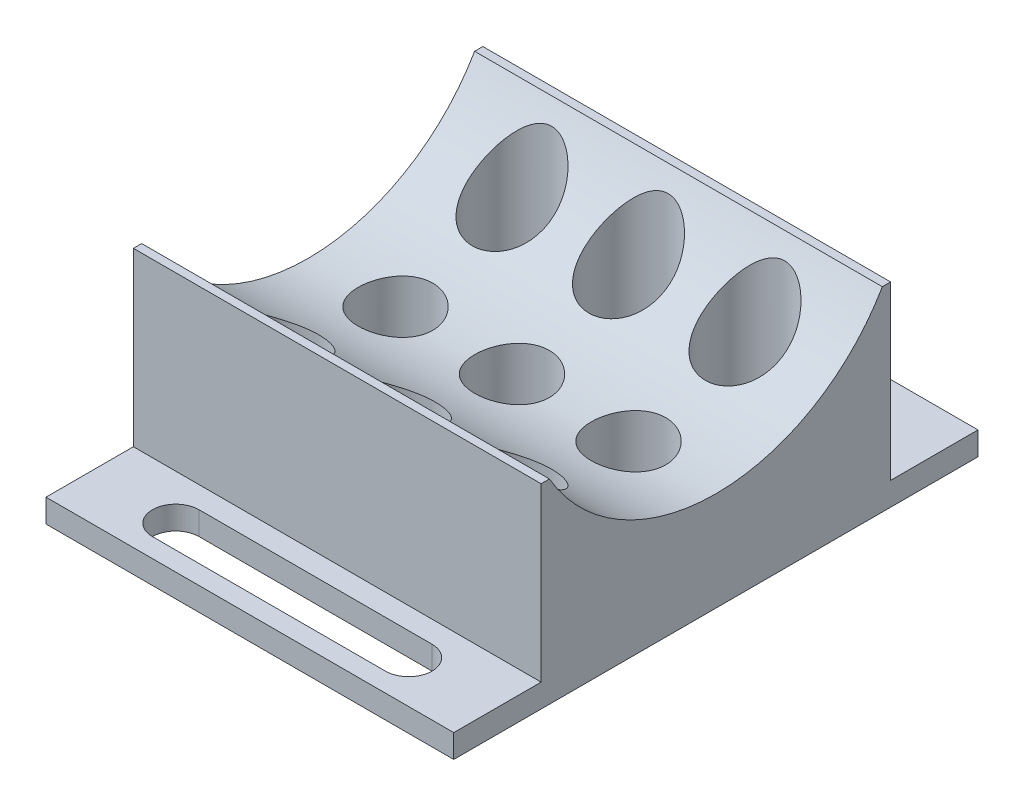
from build123d import *

# Parameters (mm, degrees)
SKETCH8_W                       = 35
SKETCH8_H                       = 30
BOSS_EXTRUDE7_DEPTH             = 80
SKETCH10_R                      = 16.5
CUT_EXTRUDE3_DEPTH              = 18.5
CUT_EXTRUDE3_DEPTH_BACK         = 18.5
SKETCH11_W                      = 38.336381606
SKETCH11_H                      = 16.50007926
CUT_EXTRUDE4_DEPTH              = 18.5
CUT_EXTRUDE4_DEPTH_BACK         = 18.5
SKETCH12_W                      = 33.824881692
SKETCH12_H                      = 15
CUT_EXTRUDE5_DEPTH              = 18.5
CUT_EXTRUDE5_DEPTH_BACK         = 18.5
SKETCH13_W                      = 45.541829225
SKETCH13_H                      = 41.48776408
CUT_EXTRUDE6_DEPTH              = 18.5
CUT_EXTRUDE6_DEPTH_BACK         = 18.5
SKETCH15_W                      = 35
SKETCH15_H                      = 7.5
BOSS_EXTRUDE9_DEPTH             = 2
CUT_EXTRUDE7_DEPTH              = 2
SKETCH18_R                      = 3.2
CUT_EXTRUDE10_DEPTH             = 9.24996037
CUT_EXTRUDE10_DEPTH_BACK        = 6.4
CUT_EXTRUDE11_REACH             = 10.25
SKETCH19_R                      = 3.4
CUT_EXTRUDE11_DIRECTION_2_DEPTH = 4.9


with BuildPart() as part:
    # Sketch8 → Boss-Extrude7 (new body)
    with BuildSketch(Plane(origin=(0, 0, 0), x_dir=(1, 0, 0), z_dir=(0, 1, 0))):
        Rectangle(SKETCH8_W, SKETCH8_H)
    extrude(amount=BOSS_EXTRUDE7_DEPTH)

    # Sketch10 → Cut-Extrude3 (cut, two sides)
    with BuildSketch(Plane(origin=(0, 0, 0), x_dir=(0, 0, -1), z_dir=(1, 0, 0))) as cut_extrude3_sk:
        with Locations((0, 40)):
            Circle(SKETCH10_R)
    extrude(amount=CUT_EXTRUDE3_DEPTH, mode=Mode.SUBTRACT)
    extrude(cut_extrude3_sk.sketch, amount=-CUT_EXTRUDE3_DEPTH_BACK, mode=Mode.SUBTRACT)

    # Sketch11 → Cut-Extrude4 (cut, two sides)
    with BuildSketch(Plane(origin=(0, 0, 0), x_dir=(0, 0, -1), z_dir=(1, 0, 0))) as cut_extrude4_sk:
        with Locations((0, 40)):
            Rectangle(SKETCH11_W, SKETCH11_H)
    extrude(amount=CUT_EXTRUDE4_DEPTH, mode=Mode.SUBTRACT)
    extrude(cut_extrude4_sk.sketch, amount=-CUT_EXTRUDE4_DEPTH_BACK, mode=Mode.SUBTRACT)

    # Sketch12 → Cut-Extrude5 (cut, two sides)
    with BuildSketch(Plane(origin=(0, 0, 0), x_dir=(0, 0, -1), z_dir=(1, 0, 0))) as cut_extrude5_sk:
        with Locations((0.439040256, 7.5)):
            Rectangle(SKETCH12_W, SKETCH12_H)
    extrude(amount=CUT_EXTRUDE5_DEPTH, mode=Mode.SUBTRACT)
    extrude(cut_extrude5_sk.sketch, amount=-CUT_EXTRUDE5_DEPTH_BACK, mode=Mode.SUBTRACT)

    # Sketch13 → Cut-Extrude6 (cut, two sides)
    with BuildSketch(Plane(origin=(0, 0, 0), x_dir=(0, 0, -1), z_dir=(1, 0, 0))) as cut_extrude6_sk:
        with Locations((-6.569234617, 60.808180877)):
            Rectangle(SKETCH13_W, SKETCH13_H)
    extrude(amount=CUT_EXTRUDE6_DEPTH, mode=Mode.SUBTRACT)
    extrude(cut_extrude6_sk.sketch, amount=-CUT_EXTRUDE6_DEPTH_BACK, mode=Mode.SUBTRACT)

    # Sketch15 → Boss-Extrude9 (add)
    with BuildSketch(Plane(origin=(0, 15, 0), x_dir=(-1, 0, 0), z_dir=(0, -1, 0))):
        with Locations((0, -18.75)):
            Rectangle(SKETCH15_W, SKETCH15_H)
        with Locations((0, 18.75)):
            Rectangle(SKETCH15_W, SKETCH15_H)
    extrude(amount=-BOSS_EXTRUDE9_DEPTH)

    # Sketch16 → Cut-Extrude7 (cut)
    with BuildSketch(Plane(origin=(0, 15, 0), x_dir=(-1, 0, 0), z_dir=(0, -1, 0))):
        with BuildLine():
            Line((10, -20.863517543), (-10, -20.863517543))
            ThreePointArc((-10, -20.863517543), (-12, -18.863517543), (-10, -16.863517543))
            Line((-10, -16.863517543), (10, -16.863517543))
            ThreePointArc((10, -16.863517543), (12, -18.863517543), (10, -20.863517543))
        make_face()
        with BuildLine():
            Line((10, 16.803450623), (-10, 16.803450623))
            ThreePointArc((-10, 16.803450623), (-12, 18.803450623), (-10, 20.803450623))
            Line((-10, 20.803450623), (10, 20.803450623))
            ThreePointArc((10, 20.803450623), (12, 18.803450623), (10, 16.803450623))
        make_face()
    extrude(amount=-CUT_EXTRUDE7_DEPTH, mode=Mode.SUBTRACT)

    # Sketch18 → Cut-Extrude10 (cut, two sides)
    with BuildSketch(Plane(origin=(0, 23.5, 0), x_dir=(1, 0, 0), z_dir=(0, 1, 0))) as cut_extrude10_sk:
        Circle(SKETCH18_R)
        with Locations((10, 0)):
            Circle(SKETCH18_R)
        with Locations((-10, 0)):
            Circle(SKETCH18_R)
    extrude(amount=CUT_EXTRUDE10_DEPTH, mode=Mode.SUBTRACT)
    extrude(cut_extrude10_sk.sketch, amount=-CUT_EXTRUDE10_DEPTH_BACK, mode=Mode.SUBTRACT)

    # Sketch19 → Cut-Extrude11 (cut, up to next)
    with BuildSketch(Plane(origin=(0, 23.5, 0), x_dir=(1, 0, 0), z_dir=(0, 1, 0)), mode=Mode.PRIVATE) as cut_extrude11_sk1:
        with Locations((-10, -10)):
            Circle(SKETCH19_R)
    cut_extrude11_tool1 = extrude(cut_extrude11_sk1.sketch, amount=CUT_EXTRUDE11_REACH, mode=Mode.PRIVATE) & part.part
    add(cut_extrude11_tool1.solids().sort_by_distance((-10, 23.5, 10))[0], mode=Mode.SUBTRACT)
    # Sketch19 → Cut-Extrude11 (cut, up to next)
    with BuildSketch(Plane(origin=(0, 23.5, 0), x_dir=(1, 0, 0), z_dir=(0, 1, 0)), mode=Mode.PRIVATE) as cut_extrude11_sk2:
        with Locations((0, -10)):
            Circle(SKETCH19_R)
    cut_extrude11_tool2 = extrude(cut_extrude11_sk2.sketch, amount=CUT_EXTRUDE11_REACH, mode=Mode.PRIVATE) & part.part
    add(cut_extrude11_tool2.solids().sort_by_distance((0, 23.5, 10))[0], mode=Mode.SUBTRACT)
    # Sketch19 → Cut-Extrude11 (cut, up to next)
    with BuildSketch(Plane(origin=(0, 23.5, 0), x_dir=(1, 0, 0), z_dir=(0, 1, 0)), mode=Mode.PRIVATE) as cut_extrude11_sk3:
        with Locations((10, -10)):
            Circle(SKETCH19_R)
    cut_extrude11_tool3 = extrude(cut_extrude11_sk3.sketch, amount=CUT_EXTRUDE11_REACH, mode=Mode.PRIVATE) & part.part
    add(cut_extrude11_tool3.solids().sort_by_distance((10, 23.5, 10))[0], mode=Mode.SUBTRACT)
    # Sketch19 → Cut-Extrude11 (cut, up to next)
    with BuildSketch(Plane(origin=(0, 23.5, 0), x_dir=(1, 0, 0), z_dir=(0, 1, 0)), mode=Mode.PRIVATE) as cut_extrude11_sk4:
        with Locations((-10, 10)):
            Circle(SKETCH19_R)
    cut_extrude11_tool4 = extrude(cut_extrude11_sk4.sketch, amount=CUT_EXTRUDE11_REACH, mode=Mode.PRIVATE) & part.part
    add(cut_extrude11_tool4.solids().sort_by_distance((-10, 23.5, -10))[0], mode=Mode.SUBTRACT)
    # Sketch19 → Cut-Extrude11 (cut, up to next)
    with BuildSketch(Plane(origin=(0, 23.5, 0), x_dir=(1, 0, 0), z_dir=(0, 1, 0)), mode=Mode.PRIVATE) as cut_extrude11_sk5:
        with Locations((0, 10)):
            Circle(SKETCH19_R)
    cut_extrude11_tool5 = extrude(cut_extrude11_sk5.sketch, amount=CUT_EXTRUDE11_REACH, mode=Mode.PRIVATE) & part.part
    add(cut_extrude11_tool5.solids().sort_by_distance((0, 23.5, -10))[0], mode=Mode.SUBTRACT)
    # Sketch19 → Cut-Extrude11 (cut, up to next)
    with BuildSketch(Plane(origin=(0, 23.5, 0), x_dir=(1, 0, 0), z_dir=(0, 1, 0)), mode=Mode.PRIVATE) as cut_extrude11_sk6:
        with Locations((10, 10)):
            Circle(SKETCH19_R)
    cut_extrude11_tool6 = extrude(cut_extrude11_sk6.sketch, amount=CUT_EXTRUDE11_REACH, mode=Mode.PRIVATE) & part.part
    add(cut_extrude11_tool6.solids().sort_by_distance((10, 23.5, -10))[0], mode=Mode.SUBTRACT)

    # Sketch19 → Cut-Extrude11 direction 2 (cut)
    with BuildSketch(Plane(origin=(0, 23.5, 0), x_dir=(1, 0, 0), z_dir=(0, 1, 0))):
        with Locations((-10, -10)):
            Circle(SKETCH19_R)
        with Locations((0, -10)):
            Circle(SKETCH19_R)
        with Locations((10, -10)):
            Circle(SKETCH19_R)
        with Locations((-10, 10)):
            Circle(SKETCH19_R)
        with Locations((0, 10)):
            Circle(SKETCH19_R)
        with Locations((10, 10)):
            Circle(SKETCH19_R)
    extrude(amount=-CUT_EXTRUDE11_DIRECTION_2_DEPTH, mode=Mode.SUBTRACT)


solid = part.part
